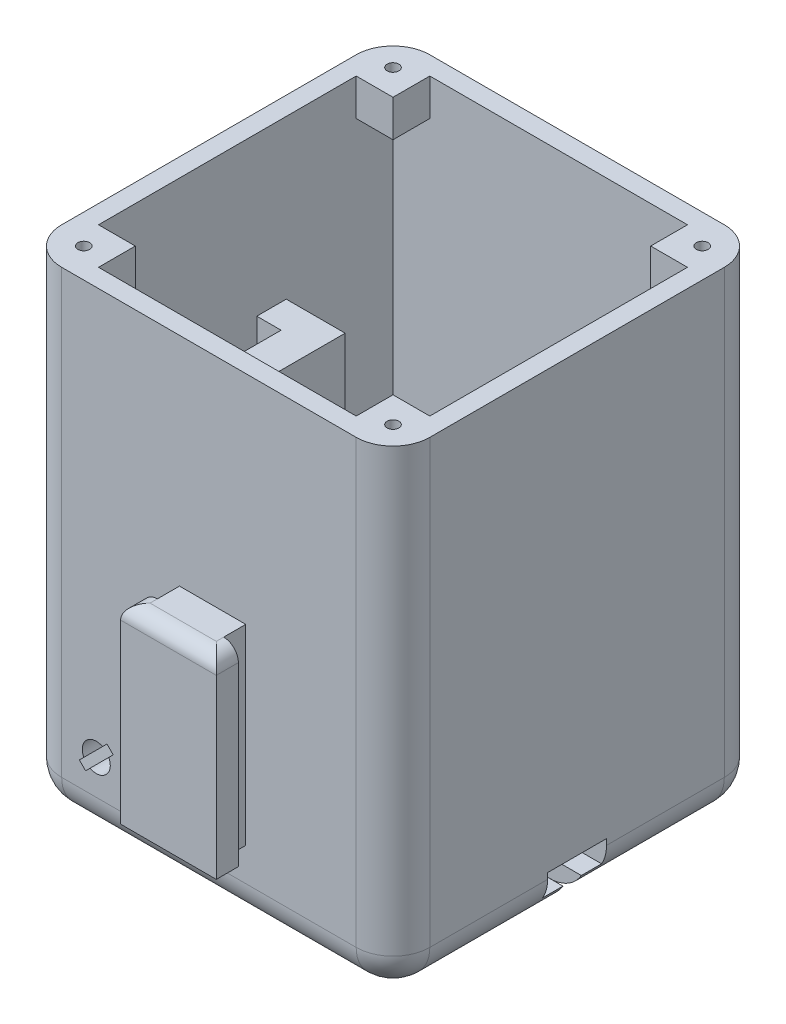
from build123d import *

# Parameters (mm, degrees)
SKETCH1_W                             = 50
SKETCH1_H                             = 50
BASE_SHELL_DEPTH                      = 65
SHELL1_T                              = -2.5
FILLET1_R                             = 5
SKETCH2_W                             = 13
SKETCH2_H                             = 26
LOCK_CONNECTOR_EXTRUDE_DEPTH          = 6
SKETCH3_W                             = 3
SKETCH3_H                             = 2
LOCK_CONNECTOR_CUT_DEPTH              = 54.350257731
LOCK_CONNECTOR_FILLET_R               = 2
SKETCH8_W                             = 45
SKETCH8_H                             = 16
BOTTOM_CONNECTOR_INSIDE_DEPTH         = 11
SKETCH10_W                            = 35.5
SKETCH10_H                            = 9.5
BOTTOM_FEMALE_BOTTOM_CUT_DEPTH        = 2.6
SKETCH7_W                             = 35.5
SKETCH7_H                             = 13.5
BOTTOM_FEMALE_TOP_CUT_DEPTH           = 3.2
ROUNDED_ENTRANCE_REACH                = 80.282
ROUNDED_ENTRANCE_DIRECTION_2_REACH    = 80.282
SKETCH22_W                            = 8
SKETCH22_H                            = 3.3
HEADER_PIN_CUT_DEPTH                  = 81.288542146
HEADER_PIN_HOLDER_REACH               = 78.23
SKETCH23_W                            = 14.435585072
SKETCH23_H                            = 2.5
SKETCH25_W                            = 2
SKETCH25_H                            = 3.1
WIRE_CUT_DEPTH                        = 72.348721082
SKETCH57_W                            = 1
SKETCH57_H                            = 2.45
PIN_STOPPER_DEPTH                     = 1
SKETCH15_W                            = 16
SKETCH15_H                            = 30
SIDE_CONNECTOR_INSIDE_DEPTH           = 8
SKETCH58_W                            = 3.3
SKETCH58_H                            = 8
CUT_EXTRUDE7_DEPTH                    = 54.350257731
SKETCH14_R                            = 1.25
LOCK_BOTTOM_SUPPORT_DEPTH             = 4.5
SKETCH61_W                            = 5
SKETCH61_H                            = 5
BOSS_EXTRUDE12_DEPTH                  = 5
MIRROR2_COPY_1_SKETCH_W               = 5
MIRROR2_COPY_1_SKETCH_H               = 5
MIRROR2_COPY_1_DEPTH                  = 5
LOCK_SUPPORT_DEPTH                    = 17
LOCK_CUT_DEPTH                        = 19.5
SKETCH11_R                            = 3.75
SPRING_GAP_DEPTH                      = 20
FLANG_GAP_DEPTH                       = 19
FLANG_SCREW_CUT_DEPTH                 = 2.5
FILLET2_R                             = 5
SKETCH59_W                            = 5.3
SKETCH59_H                            = 8
SIDE_CONNECTOR_BOTTOM_SUPPORT_DEPTH   = 0.5
SKETCH60_W                            = 8
SKETCH60_H                            = 6
BOTTOM_CONNECTOR_BOTTOM_SUPPORT_DEPTH = 0.5


with BuildPart() as part:
    # Sketch1 → base shell (new body)
    with BuildSketch(Plane(origin=(0, 0, 0), x_dir=(1, 0, 0), z_dir=(0, 1, 0))):
        Rectangle(SKETCH1_W, SKETCH1_H)
    extrude(amount=BASE_SHELL_DEPTH)

    # Shell1
    shell1_openings = [part.faces().sort_by_distance(p)[0] for p in [
        (0, 65, 0),
    ]]
    offset(amount=SHELL1_T, openings=shell1_openings, kind=Kind.INTERSECTION)

    # Fillet1
    fillet1_edges = [part.edges().sort_by_distance(p)[0] for p in [
        (0, 0, -25),
        (25, 0, 0),
        (0, 0, 25),
        (-25, 0, 0),
        (-25, 32.5, -25),
        (25, 32.5, -25),
        (25, 32.5, 25),
        (-25, 32.5, 25),
    ]]
    fillet(fillet1_edges, radius=FILLET1_R)

    # Sketch2 → lock connector extrude (add)
    with BuildSketch(Plane.XY.offset(25)):
        with Locations((0.5, 22.5)):
            Rectangle(SKETCH2_W, SKETCH2_H)
    extrude(amount=LOCK_CONNECTOR_EXTRUDE_DEPTH)

    # Sketch3 → lock connector cut (cut, through all)
    with BuildSketch(Plane(origin=(0, 35.5, 0), x_dir=(0, 0, -1), z_dir=(0, 1, 0))):
        with Locations((-26.5, -6)):
            Rectangle(SKETCH3_W, SKETCH3_H)
        with Locations((-26.5, 5)):
            Rectangle(SKETCH3_W, SKETCH3_H)
    extrude(amount=-LOCK_CONNECTOR_CUT_DEPTH, mode=Mode.SUBTRACT)

    # lock connector fillet
    lock_connector_fillet_edges = [part.edges().sort_by_distance(p)[0] for p in [
        (7, 35.5, 29.5),
        (-6, 35.5, 29.5),
        (0.5, 35.5, 31),
    ]]
    fillet(lock_connector_fillet_edges, radius=LOCK_CONNECTOR_FILLET_R)

    # Sketch8 → bottom connector inside (add)
    with BuildSketch(Plane(origin=(0, 2.5, 0), x_dir=(1, 0, 0), z_dir=(0, 1, 0))):
        Rectangle(SKETCH8_W, SKETCH8_H)
    extrude(amount=BOTTOM_CONNECTOR_INSIDE_DEPTH)

    # Sketch10 → bottom female bottom cut (cut)
    with BuildSketch(Plane.XZ):
        with Locations((-7.25, 0)):
            Rectangle(SKETCH10_W, SKETCH10_H)
    bottom_female_bottom_cut = extrude(amount=-BOTTOM_FEMALE_BOTTOM_CUT_DEPTH, mode=Mode.SUBTRACT)

    # Sketch7 → bottom female top cut (cut)
    with BuildSketch(Plane(origin=(0, 2.6, 0), x_dir=(-1, 0, 0), z_dir=(0, -1, 0))):
        with Locations((7.25, 0)):
            Rectangle(SKETCH7_W, SKETCH7_H)
    bottom_female_top_cut = extrude(amount=-BOTTOM_FEMALE_TOP_CUT_DEPTH, mode=Mode.SUBTRACT)

    # rounded entrance: up to this face of the body (flat: up to its plane)
    rounded_entrance_end = Plane(part.part.faces().sort_by_distance((-7.175733888, 4.204259527, -6.75))[0])
    # Sketch26 → rounded entrance (cut, up to the picked face)
    with BuildSketch(Plane.XY.offset(-4.75), mode=Mode.PRIVATE) as rounded_entrance_sk1:
        with BuildLine():
            Line((-16, 2.6), (-24.38634244, 2.6))
            ThreePointArc((-24.38634244, 2.6), (-22.549509757, 0.698837366), (-20, 0))
            Line((-20, 0), (-18.5, 0))
            ThreePointArc((-18.5, 0), (-17.773607635, 1.80346888), (-16, 2.6))
        make_face()
    rounded_entrance_tool1 = split(extrude(rounded_entrance_sk1.sketch, amount=-ROUNDED_ENTRANCE_REACH, mode=Mode.PRIVATE), bisect_by=rounded_entrance_end, keep=Keep.BOTH, mode=Mode.PRIVATE)
    rounded_entrance = rounded_entrance_tool1.solids().sort_by(Axis((-20.596969, 1.517539, -4.75), (0, 0, -1)))[0]
    add(rounded_entrance, mode=Mode.SUBTRACT)

    # rounded entrance direction 2: up to this face of the body (flat: up to its plane)
    rounded_entrance_direction_2_end = Plane(part.part.faces().sort_by_distance((-7.175733888, 4.204259527, 6.75))[0])
    # Sketch26 → rounded entrance direction 2 (cut, up to the picked face)
    with BuildSketch(Plane.XY.offset(-4.75), mode=Mode.PRIVATE) as rounded_entrance_direction_2_sk1:
        with BuildLine():
            Line((-16, 2.6), (-24.38634244, 2.6))
            ThreePointArc((-24.38634244, 2.6), (-22.549509757, 0.698837366), (-20, 0))
            Line((-20, 0), (-18.5, 0))
            ThreePointArc((-18.5, 0), (-17.773607635, 1.80346888), (-16, 2.6))
        make_face()
    rounded_entrance_direction_2_tool1 = split(extrude(rounded_entrance_direction_2_sk1.sketch, amount=ROUNDED_ENTRANCE_DIRECTION_2_REACH, mode=Mode.PRIVATE), bisect_by=rounded_entrance_direction_2_end, keep=Keep.BOTH, mode=Mode.PRIVATE)
    rounded_entrance_direction_2 = rounded_entrance_direction_2_tool1.solids().sort_by(Axis((-20.596969, 1.517539, -4.75), (0, 0, 1)))[0]
    add(rounded_entrance_direction_2, mode=Mode.SUBTRACT)

    # Sketch22 → header pin cut (cut, through all)
    with BuildSketch(Plane.ZY.offset(-10.5)):
        with Locations((0, 4.15)):
            Rectangle(SKETCH22_W, SKETCH22_H)
    extrude(amount=-HEADER_PIN_CUT_DEPTH, mode=Mode.SUBTRACT)

    # Sketch23 → header pin holder (cut, up to next)
    with BuildSketch(Plane.XZ, mode=Mode.PRIVATE) as header_pin_holder_sk1:
        with Locations((17.717792536, 0)):
            Rectangle(SKETCH23_W, SKETCH23_H)
    header_pin_holder_tool1 = extrude(header_pin_holder_sk1.sketch, amount=-HEADER_PIN_HOLDER_REACH, mode=Mode.PRIVATE) & part.part
    add(header_pin_holder_tool1.solids().sort_by_distance((17.717793, 0, 0))[0], mode=Mode.SUBTRACT)

    # Sketch25 → wire cut (cut, through all)
    with BuildSketch(Plane(origin=(0, 5.8, 0), x_dir=(-1, 0, 0), z_dir=(0, -1, 0))):
        with Locations((-16.5, 0)):
            Rectangle(SKETCH25_W, SKETCH25_H)
    extrude(amount=-WIRE_CUT_DEPTH, mode=Mode.SUBTRACT)

    # Sketch57 → pin stopper (add)
    with BuildSketch(Plane.XZ.offset(-5.8)):
        with Locations((16.3, 2.775)):
            Rectangle(SKETCH57_W, SKETCH57_H)
        with Locations((16.3, -2.775)):
            Rectangle(SKETCH57_W, SKETCH57_H)
    extrude(amount=PIN_STOPPER_DEPTH)

    # Sketch15 → side connector inside (add)
    with BuildSketch(Plane(origin=(-22.5, 0, 0), x_dir=(0, 0, -1), z_dir=(1, 0, 0))):
        with Locations((0, 28.5)):
            Rectangle(SKETCH15_W, SKETCH15_H)
    extrude(amount=SIDE_CONNECTOR_INSIDE_DEPTH)

    # side connector mirror: bottom female bottom cut, bottom female top cut, rounded entrance, rounded entrance direction 2 across plane
    add(bottom_female_bottom_cut.mirror(Plane(origin=(-12.5, 12.5, 0), x_dir=(0, 0, 1), z_dir=(0.7071067811865488, -0.7071067811865464, 0))), mode=Mode.SUBTRACT)
    add(bottom_female_top_cut.mirror(Plane(origin=(-12.5, 12.5, 0), x_dir=(0, 0, 1), z_dir=(0.7071067811865488, -0.7071067811865464, 0))), mode=Mode.SUBTRACT)
    add(rounded_entrance.mirror(Plane(origin=(-12.5, 12.5, 0), x_dir=(0, 0, 1), z_dir=(0.7071067811865488, -0.7071067811865464, 0))), mode=Mode.SUBTRACT)
    add(rounded_entrance_direction_2.mirror(Plane(origin=(-12.5, 12.5, 0), x_dir=(0, 0, 1), z_dir=(0.7071067811865488, -0.7071067811865464, 0))), mode=Mode.SUBTRACT)

    # Sketch58 → Cut-Extrude7 (cut, through all)
    with BuildSketch(Plane.XZ.offset(-35.5)):
        with Locations((-20.85, 0)):
            Rectangle(SKETCH58_W, SKETCH58_H)
    extrude(amount=-CUT_EXTRUDE7_DEPTH, mode=Mode.SUBTRACT)

    # Sketch14 → Lock bottom support (add)
    with BuildSketch(Plane.XY.offset(-6.75)):
        with Locations((-15.3, 9.7)):
            Circle(SKETCH14_R)
    extrude(amount=LOCK_BOTTOM_SUPPORT_DEPTH)

    # Sketch61 → Boss-Extrude12 (add)
    with BuildSketch(Plane.ZY.offset(-22.5)):
        with Locations((-20, 62.5)):
            Rectangle(SKETCH61_W, SKETCH61_H)
    boss_extrude12 = extrude(amount=BOSS_EXTRUDE12_DEPTH)

    # Sketch29 → M2 Tapped Hole1 (revolve, cut)
    with BuildSketch(Plane(origin=(21, 65, -21), x_dir=(0, 0, 1), z_dir=(1, 0, 0))):
        Polygon((0, 0), (0, 5.480688495), (0.8, 5), (0.8, 0), align=None)
    m2_tapped_hole1 = revolve(axis=Axis((21, 71.35, -21), (0, -1, 0)), mode=Mode.SUBTRACT)

    # Mirror1: Boss-Extrude12, M2 Tapped Hole1 across plane
    add(boss_extrude12.mirror(Plane(origin=(0, 0, 0), x_dir=(0, 0, 1), z_dir=(1, 0, 0))))
    add(m2_tapped_hole1.mirror(Plane(origin=(0, 0, 0), x_dir=(0, 0, 1), z_dir=(1, 0, 0))), mode=Mode.SUBTRACT)

    # Mirror2: Boss-Extrude12, M2 Tapped Hole1 across plane
    add(boss_extrude12.mirror(Plane.XY))
    add(m2_tapped_hole1.mirror(Plane.XY), mode=Mode.SUBTRACT)

    # Mirror2 copy 1 sketch → Mirror2 copy 1 (add)
    with BuildSketch(Plane(origin=(-22.5, 0, 0), x_dir=(0, 0, -1), z_dir=(1, 0, 0))):
        with Locations((-20, 62.5)):
            Rectangle(MIRROR2_COPY_1_SKETCH_W, MIRROR2_COPY_1_SKETCH_H)
    extrude(amount=MIRROR2_COPY_1_DEPTH)

    # Mirror2 copy 2 sketch → Mirror2 copy 2 (revolve, cut)
    with BuildSketch(Plane(origin=(-21, 65, 21), x_dir=(0, 0, -1), z_dir=(-1, 0, 0))):
        Polygon((0, 0), (0, 5.480688495), (0.8, 5), (0.8, 0), align=None)
    revolve(axis=Axis((-21, 71.35, 21), (0, -1, 0)), mode=Mode.SUBTRACT)

    # Sketch41 → lock support (add)
    with BuildSketch(Plane(origin=(0, 2.5, 0), x_dir=(1, 0, 0), z_dir=(0, 1, 0))):
        Polygon((-22.5, -22.5), (-8.5, -22.5), (-8.5, -8), (-22.5, -8), (-22.5, -17), align=None)
    extrude(amount=LOCK_SUPPORT_DEPTH)

    # Sketch6 → lock cut (cut)
    with BuildSketch(Plane.XY.offset(25)):
        with BuildLine():
            ThreePointArc((-16.15049081, 8.000981053), (-16.643502884, 8.356497116), (-16.999018947, 8.84950919))
            Line((-16.999018947, 8.84950919), (-17.600059711, 8.248468426))
            Line((-17.600059711, 8.248468426), (-16.751531574, 7.399940289))
            Line((-16.751531574, 7.399940289), (-16.15049081, 8.000981053))
        make_face()
        with BuildLine():
            ThreePointArc((-14.44950919, 11.399018947), (-13.956497116, 11.043502884), (-13.600981053, 10.55049081))
            Line((-13.600981053, 10.55049081), (-12.999940289, 11.151531574))
            Line((-12.999940289, 11.151531574), (-13.848468426, 12.000059711))
            Line((-13.848468426, 12.000059711), (-14.44950919, 11.399018947))
        make_face()
        with BuildLine():
            ThreePointArc((-13.4, 9.7), (-13.4509278, 10.136957664), (-13.600981053, 10.55049081))
            ThreePointArc((-13.600981053, 10.55049081), (-13.956497116, 11.043502884), (-14.44950919, 11.399018947))
            ThreePointArc((-14.44950919, 11.399018947), (-16.643502884, 11.043502884), (-16.999018947, 8.84950919))
            ThreePointArc((-16.999018947, 8.84950919), (-16.643502884, 8.356497116), (-16.15049081, 8.000981053))
            ThreePointArc((-16.15049081, 8.000981053), (-14.301484236, 8.083532781), (-13.4, 9.7))
        make_face()
    extrude(amount=-LOCK_CUT_DEPTH, mode=Mode.SUBTRACT)

    # Sketch11 → Spring gap (cut)
    with BuildSketch(Plane.XY.offset(-2.5)):
        with Locations((-15.3, 9.7)):
            Circle(SKETCH11_R)
    extrude(amount=SPRING_GAP_DEPTH, mode=Mode.SUBTRACT)

    # Sketch12 → Flang gap (cut)
    with BuildSketch(Plane.XY.offset(-2.5)):
        with BuildLine():
            Line((-15.3, 9.7), (-13.274593025, 3.523615411))
            ThreePointArc((-13.274593025, 3.523615411), (-19.63620247, 4.857753812), (-21.661609445, 11.034138401))
            Line((-21.661609445, 11.034138401), (-15.3, 9.7))
        make_face()
    extrude(amount=FLANG_GAP_DEPTH, mode=Mode.SUBTRACT)

    # Sketch52 → flang screw cut (cut)
    with BuildSketch(Plane(origin=(0, 0, 6.75), x_dir=(-1, 0, 0), z_dir=(0, 0, -1))):
        with BuildLine():
            Line((21.568994271, 7.982527778), (25, 5))
            add(Edge.make_bspline(
                [(25, 5), (26.808053779, 2.347485232), (22.598490609, -3.321737418), (20, 0)],
                knots=[0, 0, 0, 0, 1, 1, 1, 1], degree=3))
            Line((20, 0), (17.017472222, 3.431005729))
            Line((17.017472222, 3.431005729), (21.568994271, 7.982527778))
        make_face()
    extrude(amount=-FLANG_SCREW_CUT_DEPTH, mode=Mode.SUBTRACT)

    # Fillet2
    fillet2_edges = [part.edges().sort_by_distance(p)[0] for p in [
        (-19.2, 5.8, -4.625),
    ]]
    fillet(fillet2_edges, radius=FILLET2_R)

    # Sketch59 → side connector bottom support (add)
    with BuildSketch(Plane.XZ.offset(-5.8)):
        with Locations((13.15, 0)):
            Rectangle(SKETCH59_W, SKETCH59_H)
    extrude(amount=SIDE_CONNECTOR_BOTTOM_SUPPORT_DEPTH)

    # Sketch60 → bottom connector bottom support (add)
    with BuildSketch(Plane.ZY.offset(19.2)):
        with Locations((0, 38.5)):
            Rectangle(SKETCH60_W, SKETCH60_H)
    extrude(amount=BOTTOM_CONNECTOR_BOTTOM_SUPPORT_DEPTH)


solid = part.part
